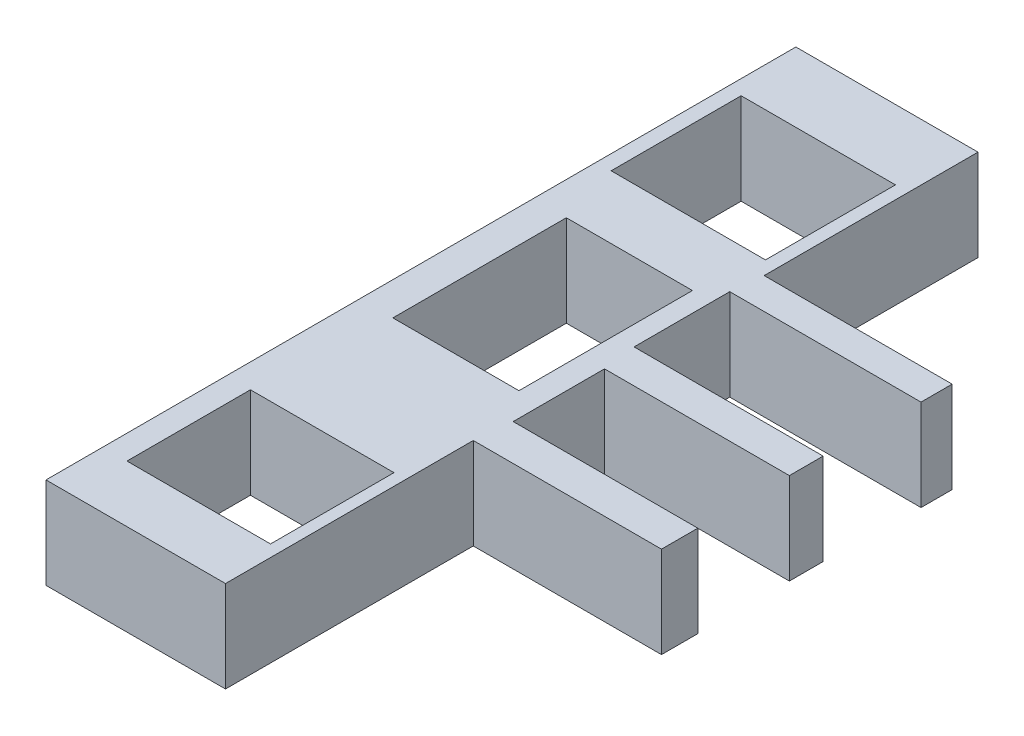
from build123d import *

# Parameters (mm, degrees)
SKETCH2_W           = 23.651183611
SKETCH2_H           = 19.920292675
SKETCH2_W_2         = 19.320685203
SKETCH2_H_2         = 26.582597918
SKETCH2_W_3         = 22
SKETCH2_H_3         = 18.920946888
BOSS_EXTRUDE1_DEPTH = 14


with BuildPart() as part:
    # Sketch2 → Boss-Extrude1 (new body)
    with BuildSketch(Plane(origin=(0, 0, 0), x_dir=(1, 0, 0), z_dir=(0, 1, 0))):
        Polygon((-27.908593219, 57.483539187), (-27.908593219, -57.424852572), (-0.405302454, -57.424852572), (-0.405302454, -19.455651499), (28.437596205, -19.455651499), (28.437596205, -13.887867334), (0.143608651, -13.887867334), (0.143608651, 0.105967325), (28.472121021, 0.105967325), (28.472121021, 5.282539019), (-0.501944112, 5.282539019), (-0.501944112, 19.945920068), (28.807431377, 19.945920068), (28.807431377, 24.716415232), (0, 24.716415232), (0, 57.483539187), align=None)
        with Locations((-13.80552661, 36.856875137)):
            Rectangle(SKETCH2_W, SKETCH2_H, mode=Mode.SUBTRACT)
        with Locations((-13.172607612, 3.945087239)):
            Rectangle(SKETCH2_W_2, SKETCH2_H_2, mode=Mode.SUBTRACT)
        with Locations((-13.207270194, -39.259962259)):
            Rectangle(SKETCH2_W_3, SKETCH2_H_3, mode=Mode.SUBTRACT)
    extrude(amount=BOSS_EXTRUDE1_DEPTH)


solid = part.part
